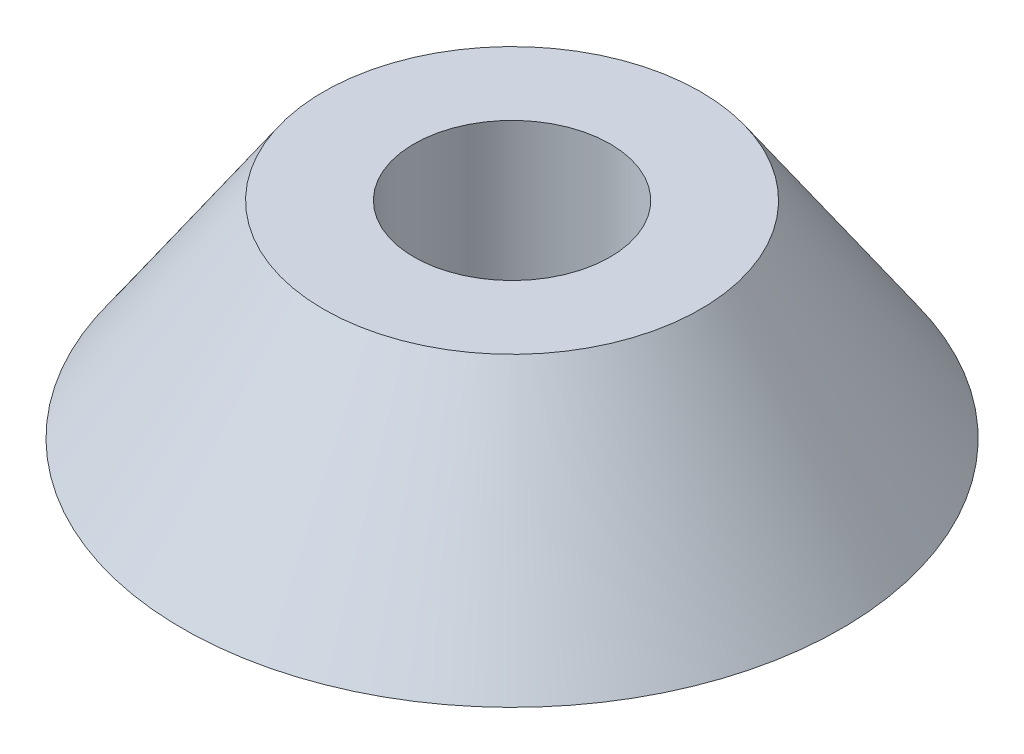
from build123d import *


with BuildPart() as part:
    # Sketch1 → Revolve1 (revolve)
    with BuildSketch(Plane.XY):
        Polygon((4.7625, 0), (4.7625, 10), (9.15, 10), (16, 0), align=None)
    revolve(axis=Axis((0, 0, 0), (0, 1, 0)))


solid = part.part
